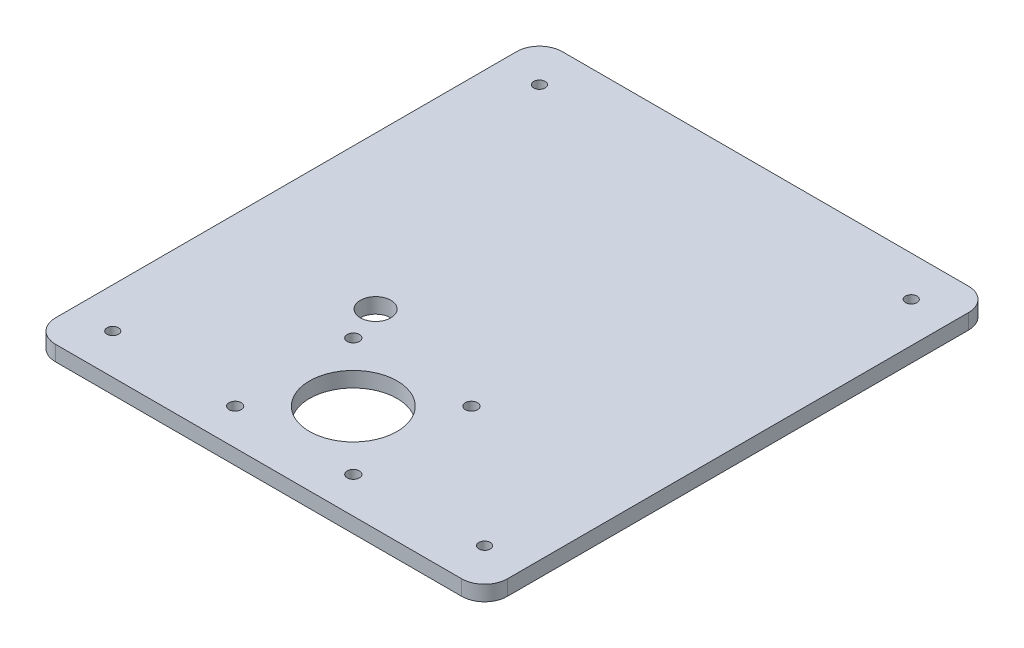
from build123d import *

# Parameters (mm, degrees)
BOSS_EXTRUDE1_DEPTH = 4
CUT_EXTRUDE1_REACH  = 6
SKETCH2_R           = 11.5
SKETCH2_R_2         = 1.6
CUT_EXTRUDE2_REACH  = 6
SKETCH4_R           = 1.5
SKETCH5_W           = 10
SKETCH5_H           = 30
BOSS_EXTRUDE2_DEPTH = 12
FILLET1_R           = 1.5
CUT_EXTRUDE3_REACH  = 6
SKETCH6_R           = 4


with BuildPart() as part:
    # Sketch1 → Boss-Extrude1 (new body)
    with BuildSketch(Plane.XZ.offset(-57.396189287)):
        with BuildLine():
            Line((117.077991716, 202.076411562), (117.077991716, 81.069101486))
            add(Edge.make_bspline(
                [(111.081646754, 75.072756524), (117.077991716, 75.072756524), (117.077991716, 81.069101486)],
                knots=[5.498396131, 5.498396131, 5.498396131, 7.067974483, 7.067974483, 7.067974483], degree=2, weights=[1, 0.707537269, 1]))
            Line((111.081646754, 75.072756524), (4.474336679, 75.072756524))
            add(Edge.make_bspline(
                [(-1.522008284, 81.069101486), (-1.522008284, 75.072756524), (4.474336679, 75.072756524)],
                knots=[5.498396131, 5.498396131, 5.498396131, 7.067974483, 7.067974483, 7.067974483], degree=2, weights=[1, 0.707537269, 1]))
            Line((-1.522008284, 81.069101486), (-1.522008284, 202.076411562))
            add(Edge.make_bspline(
                [(4.474336679, 208.072756524), (-1.522008284, 208.072756524), (-1.522008284, 202.076411562)],
                knots=[5.498396131, 5.498396131, 5.498396131, 7.067974483, 7.067974483, 7.067974483], degree=2, weights=[1, 0.707537269, 1]))
            Line((4.474336679, 208.072756524), (111.081646754, 208.072756524))
            add(Edge.make_bspline(
                [(117.077991716, 202.076411562), (117.077991716, 208.072756524), (111.081646754, 208.072756524)],
                knots=[5.498396131, 5.498396131, 5.498396131, 7.067974483, 7.067974483, 7.067974483], degree=2, weights=[1, 0.707537269, 1]))
        make_face()
    extrude(amount=BOSS_EXTRUDE1_DEPTH)

    # Sketch2 → Cut-Extrude1 (cut, up to next)
    with BuildSketch(Plane.XZ.offset(-53.396189287), mode=Mode.PRIVATE) as cut_extrude1_sk1:
        with Locations((57.631208462, 183.071537466)):
            Circle(SKETCH2_R)
    cut_extrude1_tool1 = extrude(cut_extrude1_sk1.sketch, amount=-CUT_EXTRUDE1_REACH, mode=Mode.PRIVATE) & part.part
    add(cut_extrude1_tool1.solids().sort_by_distance((57.631208, 53.396189, 183.071537))[0], mode=Mode.SUBTRACT)
    # Sketch2 → Cut-Extrude1 (cut, up to next)
    with BuildSketch(Plane.XZ.offset(-53.396189287), mode=Mode.PRIVATE) as cut_extrude1_sk2:
        with Locations((73.131208462, 198.571537436)):
            Circle(SKETCH2_R_2)
    cut_extrude1_tool2 = extrude(cut_extrude1_sk2.sketch, amount=-CUT_EXTRUDE1_REACH, mode=Mode.PRIVATE) & part.part
    add(cut_extrude1_tool2.solids().sort_by_distance((73.131208, 53.396189, 198.571537))[0], mode=Mode.SUBTRACT)
    # Sketch2 → Cut-Extrude1 (cut, up to next)
    with BuildSketch(Plane.XZ.offset(-53.396189287), mode=Mode.PRIVATE) as cut_extrude1_sk3:
        with Locations((42.131208462, 198.571537436)):
            Circle(SKETCH2_R_2)
    cut_extrude1_tool3 = extrude(cut_extrude1_sk3.sketch, amount=-CUT_EXTRUDE1_REACH, mode=Mode.PRIVATE) & part.part
    add(cut_extrude1_tool3.solids().sort_by_distance((42.131208, 53.396189, 198.571537))[0], mode=Mode.SUBTRACT)
    # Sketch2 → Cut-Extrude1 (cut, up to next)
    with BuildSketch(Plane.XZ.offset(-53.396189287), mode=Mode.PRIVATE) as cut_extrude1_sk4:
        with Locations((42.131208462, 167.571537436)):
            Circle(SKETCH2_R_2)
    cut_extrude1_tool4 = extrude(cut_extrude1_sk4.sketch, amount=-CUT_EXTRUDE1_REACH, mode=Mode.PRIVATE) & part.part
    add(cut_extrude1_tool4.solids().sort_by_distance((42.131208, 53.396189, 167.571537))[0], mode=Mode.SUBTRACT)
    # Sketch2 → Cut-Extrude1 (cut, up to next)
    with BuildSketch(Plane.XZ.offset(-53.396189287), mode=Mode.PRIVATE) as cut_extrude1_sk5:
        with Locations((73.131208462, 167.571537436)):
            Circle(SKETCH2_R_2)
    cut_extrude1_tool5 = extrude(cut_extrude1_sk5.sketch, amount=-CUT_EXTRUDE1_REACH, mode=Mode.PRIVATE) & part.part
    add(cut_extrude1_tool5.solids().sort_by_distance((73.131208, 53.396189, 167.571537))[0], mode=Mode.SUBTRACT)

    # Sketch4 → Cut-Extrude2 (cut, up to next)
    with BuildSketch(Plane.XZ.offset(-53.396189287), mode=Mode.PRIVATE) as cut_extrude2_sk1:
        with Locations((8.994115753, 197.556632488)):
            Circle(SKETCH4_R)
    cut_extrude2_tool1 = extrude(cut_extrude2_sk1.sketch, amount=-CUT_EXTRUDE2_REACH, mode=Mode.PRIVATE) & part.part
    add(cut_extrude2_tool1.solids().sort_by_distance((8.994116, 53.396189, 197.556632))[0], mode=Mode.SUBTRACT)
    # Sketch4 → Cut-Extrude2 (cut, up to next)
    with BuildSketch(Plane.XZ.offset(-53.396189287), mode=Mode.PRIVATE) as cut_extrude2_sk2:
        with Locations((106.56186768, 197.556632488)):
            Circle(SKETCH4_R)
    cut_extrude2_tool2 = extrude(cut_extrude2_sk2.sketch, amount=-CUT_EXTRUDE2_REACH, mode=Mode.PRIVATE) & part.part
    add(cut_extrude2_tool2.solids().sort_by_distance((106.561868, 53.396189, 197.556632))[0], mode=Mode.SUBTRACT)
    # Sketch4 → Cut-Extrude2 (cut, up to next)
    with BuildSketch(Plane.XZ.offset(-53.396189287), mode=Mode.PRIVATE) as cut_extrude2_sk3:
        with Locations((8.994115753, 85.588880561)):
            Circle(SKETCH4_R)
    cut_extrude2_tool3 = extrude(cut_extrude2_sk3.sketch, amount=-CUT_EXTRUDE2_REACH, mode=Mode.PRIVATE) & part.part
    add(cut_extrude2_tool3.solids().sort_by_distance((8.994116, 53.396189, 85.588881))[0], mode=Mode.SUBTRACT)
    # Sketch4 → Cut-Extrude2 (cut, up to next)
    with BuildSketch(Plane.XZ.offset(-53.396189287), mode=Mode.PRIVATE) as cut_extrude2_sk4:
        with Locations((106.56186768, 85.588880561)):
            Circle(SKETCH4_R)
    cut_extrude2_tool4 = extrude(cut_extrude2_sk4.sketch, amount=-CUT_EXTRUDE2_REACH, mode=Mode.PRIVATE) & part.part
    add(cut_extrude2_tool4.solids().sort_by_distance((106.561868, 53.396189, 85.588881))[0], mode=Mode.SUBTRACT)

    # Sketch5 → Boss-Extrude2 (add)
    with BuildSketch(Plane.XZ.offset(-53.396189287)):
        with Locations((57.477991716, 148.072756524)):
            Rectangle(SKETCH5_W, SKETCH5_H)
    extrude(amount=BOSS_EXTRUDE2_DEPTH)

    # Fillet1
    fillet1_edges = [part.edges().sort_by_distance(p)[0] for p in [
        (52.477991716, 53.396189287, 148.072756524),
        (52.477991716, 47.396189287, 163.072756524),
        (57.477991716, 53.396189287, 133.072756524),
        (52.477991716, 47.396189287, 133.072756524),
        (62.477991716, 53.396189287, 148.072756524),
        (62.477991716, 47.396189287, 133.072756524),
        (57.477991716, 53.396189287, 163.072756524),
        (62.477991716, 47.396189287, 163.072756524),
    ]]
    fillet(fillet1_edges, radius=FILLET1_R)

    # Sketch6 → Cut-Extrude3 (cut, up to next)
    with BuildSketch(Plane.XZ.offset(-53.396189287), mode=Mode.PRIVATE) as cut_extrude3_sk1:
        with Locations((38.477991716, 158.072756524)):
            Circle(SKETCH6_R)
    cut_extrude3_tool1 = extrude(cut_extrude3_sk1.sketch, amount=-CUT_EXTRUDE3_REACH, mode=Mode.PRIVATE) & part.part
    add(cut_extrude3_tool1.solids().sort_by_distance((38.477992, 53.396189, 158.072757))[0], mode=Mode.SUBTRACT)


solid = part.part
